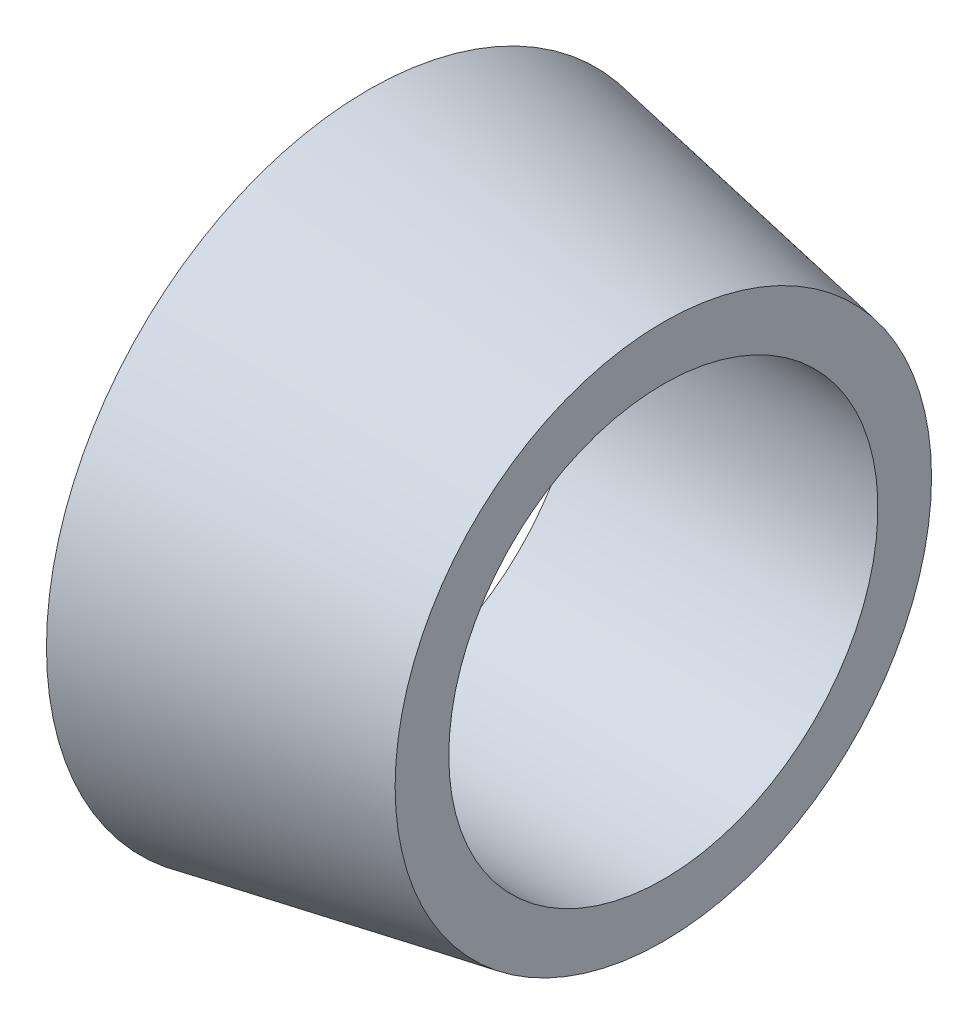
from build123d import *


with BuildPart() as part:
    # Szkic1 → Obrót1 (revolve)
    with BuildSketch(Plane.XY):
        Polygon((0, 4), (0, 6), (5.5, 5), (5.5, 4), align=None)
    revolve(axis=Axis((0, 0, 0), (1, 0, 0)))


solid = part.part
